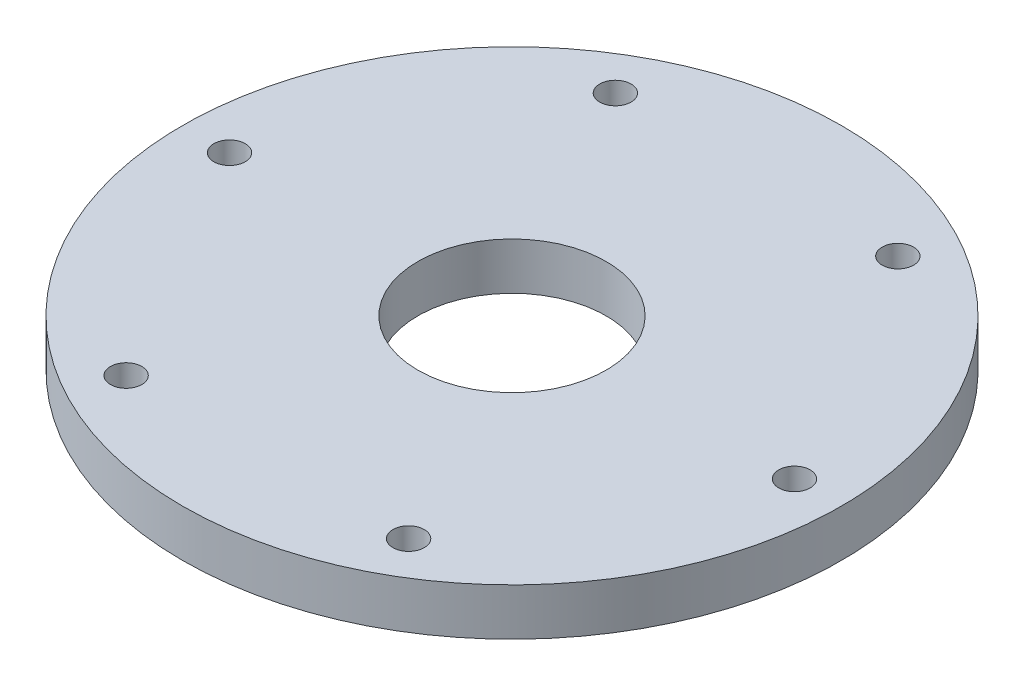
from build123d import *

# Parameters (mm, degrees)
SKETCH1_R                       = 66.675
SKETCH1_R_2                     = 19.05
BOSS_EXTRUDE1_DEPTH             = 9.525
SKETCH2_W                       = 3.175
SKETCH2_H                       = 3.81
F_1_4_0_25_DIAMETER_HOLE1_D     = 6.35
F_1_4_0_25_DIAMETER_HOLE1_DEPTH = 9.526
CIRPATTERN1_COUNT               = 6


with BuildPart() as part:
    # Sketch1 → Boss-Extrude1 (new body)
    with BuildSketch(Plane(origin=(0, 0, 0), x_dir=(1, 0, 0), z_dir=(0, 1, 0))):
        Circle(SKETCH1_R)
        Circle(SKETCH1_R_2, mode=Mode.SUBTRACT)
    extrude(amount=BOSS_EXTRUDE1_DEPTH)

    # Sketch2 → Cut-Revolve1 (revolve, cut)
    with BuildSketch(Plane.XY):
        with Locations((42.8625, 1.905)):
            Rectangle(SKETCH2_W, SKETCH2_H)
    revolve(axis=Axis((0, -0.47625, 0), (0, 1, 0)), mode=Mode.SUBTRACT)

    # 1/4 (0.25) Diameter Hole1
    with Locations(Plane(origin=(0, 9.525, 0), x_dir=(1, 0, 0), z_dir=(0, 1, 0))):
        with Locations((57.15, 0)):
            f_1_4_0_25_diameter_hole1 = Hole(F_1_4_0_25_DIAMETER_HOLE1_D / 2, depth=F_1_4_0_25_DIAMETER_HOLE1_DEPTH)

    # CirPattern1: 1/4 (0.25) Diameter Hole1 ×6 about axis
    cirpattern1_axis = Axis((0, 0, 0), (0, 1, 0))
    for i in range(1, CIRPATTERN1_COUNT):
        add(f_1_4_0_25_diameter_hole1.rotate(cirpattern1_axis, i * 360 / CIRPATTERN1_COUNT), mode=Mode.SUBTRACT)


solid = part.part
